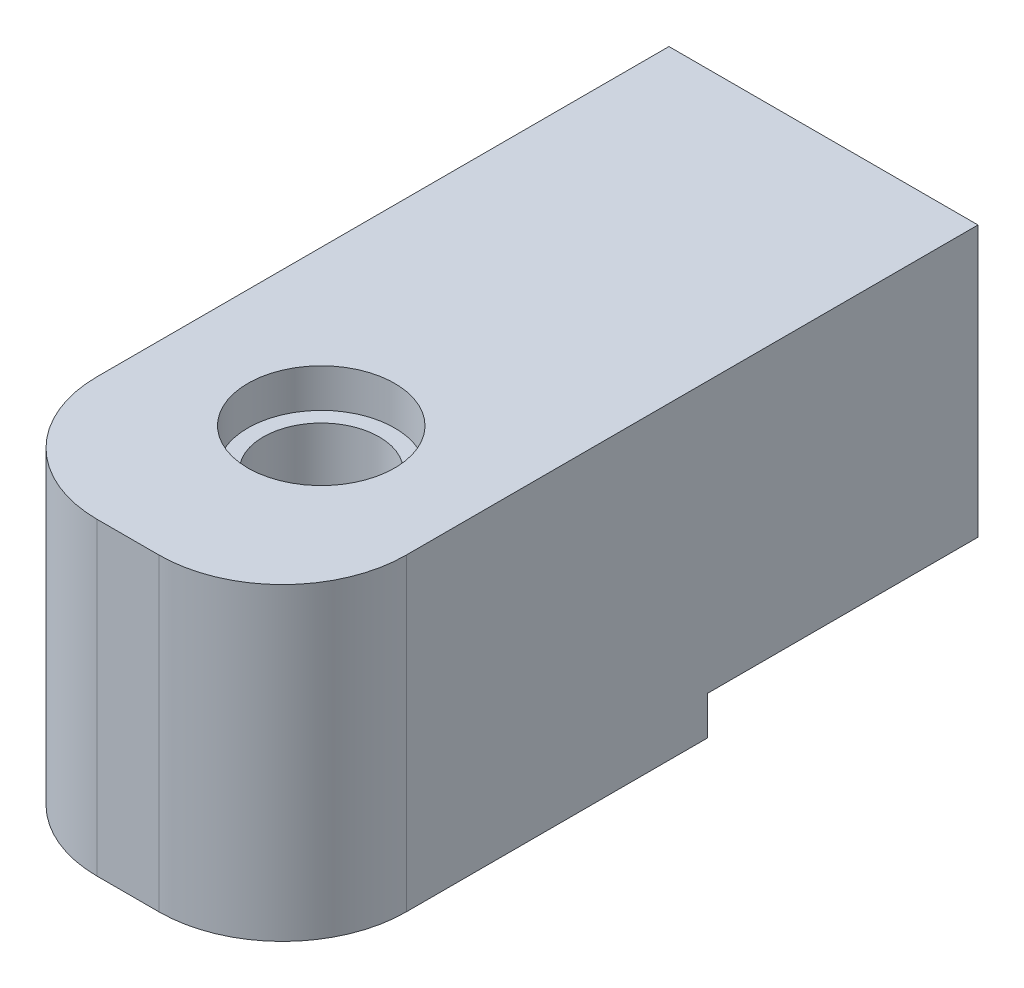
from build123d import *

# Parameters (mm, degrees)
SKETCH1_W           = 25.4
SKETCH1_H           = 25.4
BOSS_EXTRUDE1_DEPTH = 57.15
FILLET2_R           = 10.16
SKETCH2_W           = 25.4
SKETCH2_H           = 22.225
CUT_EXTRUDE2_DEPTH  = 3.175
SKETCH3_R           = 4.7625
CUT_EXTRUDE3_DEPTH  = 22.225
SKETCH4_R           = 6.0325
CUT_EXTRUDE4_DEPTH  = 3.175
SKETCH5_R           = 6.35
CUT_EXTRUDE5_DEPTH  = 30.1752


with BuildPart() as part:
    # Sketch1 → Boss-Extrude1 (new body)
    with BuildSketch(Plane.XY):
        Rectangle(SKETCH1_W, SKETCH1_H)
    extrude(amount=BOSS_EXTRUDE1_DEPTH)

    # Fillet2
    fillet2_edges = [part.edges().sort_by_distance(p)[0] for p in [
        (-12.7, 0, 57.15),
        (12.7, 0, 57.15),
    ]]
    fillet(fillet2_edges, radius=FILLET2_R)

    # Sketch2 → Cut-Extrude2 (cut)
    with BuildSketch(Plane.XZ.offset(12.7)):
        with Locations((0, 11.1125)):
            Rectangle(SKETCH2_W, SKETCH2_H)
    extrude(amount=-CUT_EXTRUDE2_DEPTH, mode=Mode.SUBTRACT)

    # Sketch3 → Cut-Extrude3 (cut)
    with BuildSketch(Plane.XZ.offset(12.7)):
        with Locations((0, 41.275)):
            Circle(SKETCH3_R)
    extrude(amount=-CUT_EXTRUDE3_DEPTH, mode=Mode.SUBTRACT)

    # Sketch4 → Cut-Extrude4 (cut)
    with BuildSketch(Plane(origin=(0, 12.7, 0), x_dir=(1, 0, 0), z_dir=(0, 1, 0))):
        with Locations((0, -41.275)):
            Circle(SKETCH4_R)
    extrude(amount=-CUT_EXTRUDE4_DEPTH, mode=Mode.SUBTRACT)

    # Sketch5 → Cut-Extrude5 (cut)
    with BuildSketch(Plane(origin=(0, 0, 0), x_dir=(-1, 0, 0), z_dir=(0, 0, -1))):
        Circle(SKETCH5_R)
    extrude(amount=-CUT_EXTRUDE5_DEPTH, mode=Mode.SUBTRACT)


solid = part.part
